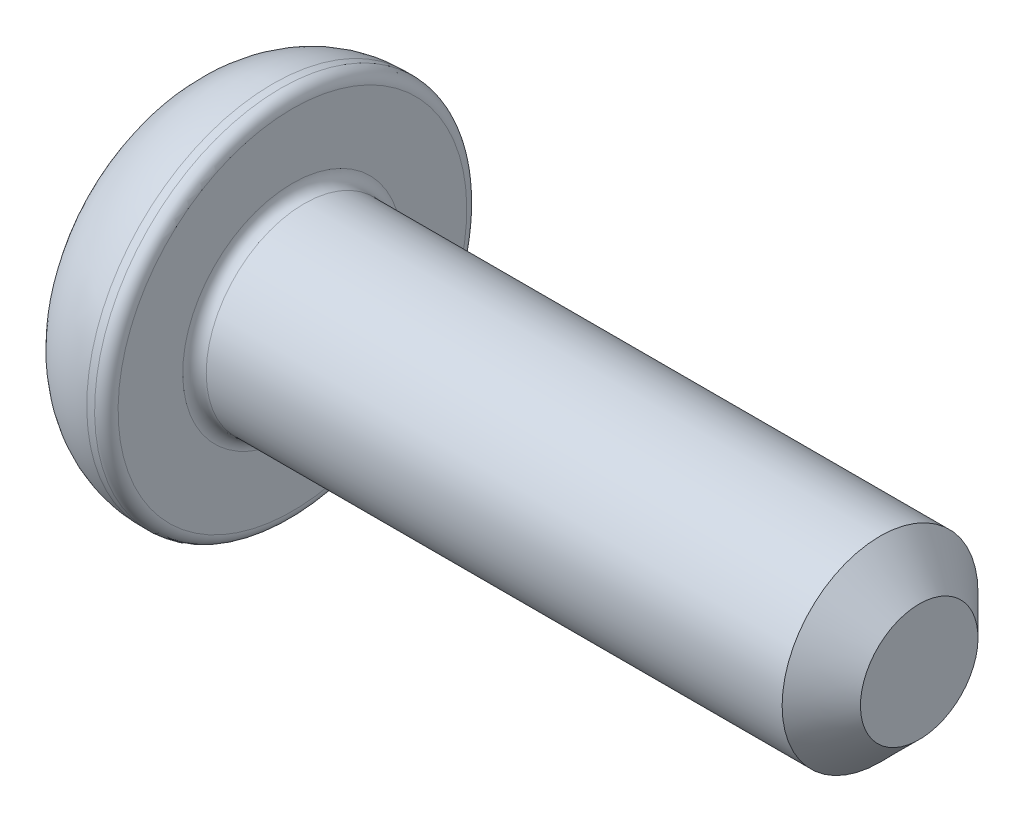
from build123d import *

# Parameters (mm, degrees)
CUT_EXTRUDE_1_DEPTH = 1.5
FILLET_1_R          = 0.3
CHAMFER_1_SIZE      = 1


with BuildPart() as part:
    # Эскиз1 → Повернуть1 (revolve)
    with BuildSketch(Plane.XY):
        with BuildLine():
            Line((0, 0), (0, 3.625))
            ThreePointArc((0, 3.625), (0.908821487, 4.451033224), (2.1, 4.75))
            Line((2.1, 4.75), (2.6, 4.75))
            Line((2.6, 4.75), (2.6, 2.5))
            Line((2.6, 2.5), (18.6, 2.5))
            Line((18.6, 2.5), (18.6, 0))
            Line((18.6, 0), (0, 0))
        make_face()
    revolve(axis=Axis((18.6, 0, 0), (-1, 0, 0)))

    # Эскиз2 → Вырез-Вытянуть1 (cut)
    with BuildSketch(Plane.ZY):
        Polygon((0.866025404, 1.5), (-0.866025404, 1.5), (-1.732050808, 0), (-0.866025404, -1.5), (0.866025404, -1.5), (1.732050808, 0), align=None)
    extrude(amount=-CUT_EXTRUDE_1_DEPTH, mode=Mode.SUBTRACT)

    # Скругление1
    fillet_1_edges = [part.edges().sort_by_distance(p)[0] for p in [
        (2.6, -2.5, 0),
        (2.6, -4.75, 0),
    ]]
    fillet(fillet_1_edges, radius=FILLET_1_R)

    # Фаска1
    chamfer_1_edges = [part.edges().sort_by_distance(p)[0] for p in [
        (18.6, -2.5, 0),
    ]]
    chamfer(chamfer_1_edges, length=CHAMFER_1_SIZE)


solid = part.part
